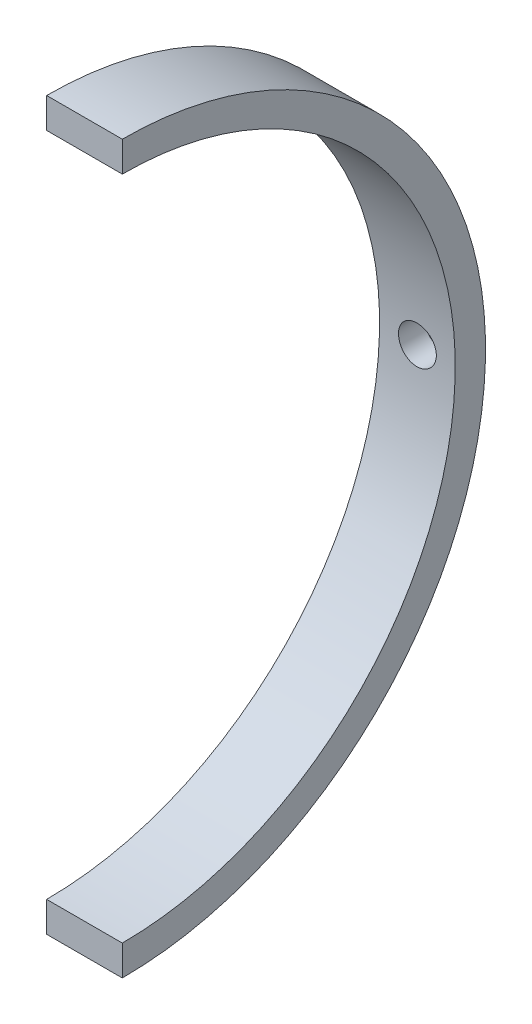
from build123d import *

# Parameters (mm, degrees)
SKICA1_W              = 5
SKICA1_H              = 2
ROTOVAT1_ANGLE        = 180
M3_Z_VIT1_D           = 2.5
M3_Z_VIT1_CSINK_D     = 3.05
M3_Z_VIT1_CSINK_ANGLE = 90


with BuildPart() as part:
    # Skica1 → Rotovat1 (revolve)
    with BuildSketch(Plane.XY):
        with Locations((-355.55, 23)):
            Rectangle(SKICA1_W, SKICA1_H)
    revolve(axis=Axis((-344.904513271, 0, 0), (-1, 0, 0)), revolution_arc=ROTOVAT1_ANGLE)

    # M3 závit1 (through all)
    with Locations(Plane(origin=(-355.55, 0, -24), x_dir=(-1, 0, 0), z_dir=(0, 0, -1))):
        with Locations((0, 0)):
            CounterSinkHole(M3_Z_VIT1_D / 2, M3_Z_VIT1_CSINK_D / 2, counter_sink_angle=M3_Z_VIT1_CSINK_ANGLE)


solid = part.part
